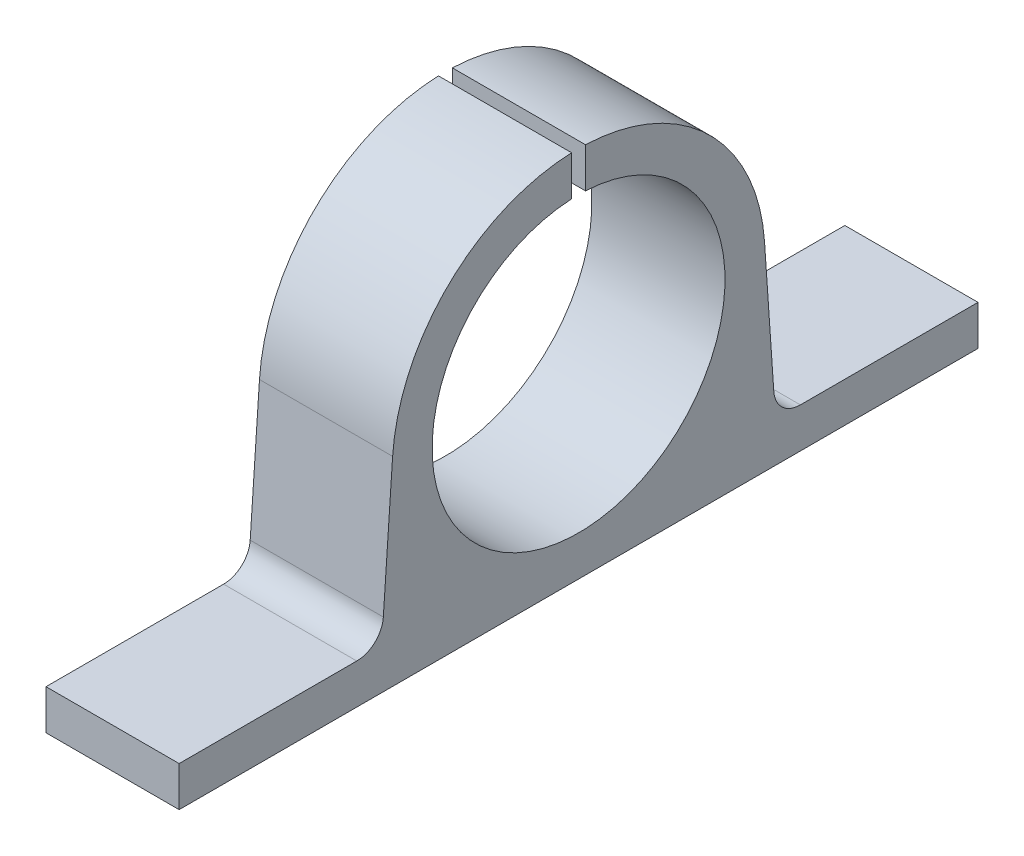
from build123d import *

# Parameters (mm, degrees)
BOSS_EXTRUDE1_DEPTH     = 10
BOSS_EXTRUDE3_DEPTH     = 10
SKETCH5_W               = 10
SKETCH5_H               = 60
BOSS_EXTRUDE4_DEPTH     = 3
FILLET2_R               = 2
SKETCH2_R               = 11
ENL_V_MAT_EXTRU_1_DEPTH = 11
ESQUISSE3_W             = 1.042364678
ESQUISSE3_H             = 5.062914153
ENL_V_MAT_EXTRU_2_DEPTH = 11


with BuildPart() as part:
    # Sketch1 → Boss-Extrude1 (new body)
    with BuildSketch(Plane(origin=(0, 0, 0), x_dir=(0, 0, -1), z_dir=(1, 0, 0))):
        with BuildLine():
            Line((-15, 0), (15, 0))
            Line((15, 0), (9.520917343, 17.058125725))
            ThreePointArc((9.520917343, 17.058125725), (0, 24), (-9.520917343, 17.058125725))
            Line((-9.520917343, 17.058125725), (-15, 0))
        make_face()
    extrude(amount=BOSS_EXTRUDE1_DEPTH)

    # Sketch4 → Boss-Extrude3 (add)
    with BuildSketch(Plane(origin=(10, 0, 0), x_dir=(0, 0, -1), z_dir=(1, 0, 0))):
        with BuildLine():
            Line((9.520917343, 17.058125725), (15, 0))
            Line((15, 0), (13.966745843, 14.964370546))
            ThreePointArc((13.966745843, 14.964370546), (0, 28), (-13.966745843, 14.964370546))
            Line((-13.966745843, 14.964370546), (-15, 0))
            Line((-15, 0), (-9.520917343, 17.058125725))
            ThreePointArc((-9.520917343, 17.058125725), (0, 24), (9.520917343, 17.058125725))
        make_face()
    extrude(amount=-BOSS_EXTRUDE3_DEPTH)

    # Sketch5 → Boss-Extrude4 (add)
    with BuildSketch(Plane.XZ):
        with Locations((5, 0)):
            Rectangle(SKETCH5_W, SKETCH5_H)
    extrude(amount=-BOSS_EXTRUDE4_DEPTH)

    # Fillet2
    fillet2_edges = [part.edges().sort_by_distance(p)[0] for p in [
        (5, 3, -14.792857143),
        (5, 3, 14.792857143),
    ]]
    fillet(fillet2_edges, radius=FILLET2_R)

    # Sketch2 → Enlèv. mat.-Extru.1 (cut, through all)
    with BuildSketch(Plane(origin=(10, 0, 0), x_dir=(0, 0, -1), z_dir=(1, 0, 0))):
        with Locations((0, 14)):
            Circle(SKETCH2_R)
    extrude(amount=-ENL_V_MAT_EXTRU_1_DEPTH, mode=Mode.SUBTRACT)

    # Esquisse3 → Enlèv. mat.-Extru.2 (cut, through all)
    with BuildSketch(Plane(origin=(10, 0, 0), x_dir=(0, 0, -1), z_dir=(1, 0, 0))):
        with Locations((0, 26.657285384)):
            Rectangle(ESQUISSE3_W, ESQUISSE3_H)
    extrude(amount=-ENL_V_MAT_EXTRU_2_DEPTH, mode=Mode.SUBTRACT)


solid = part.part
